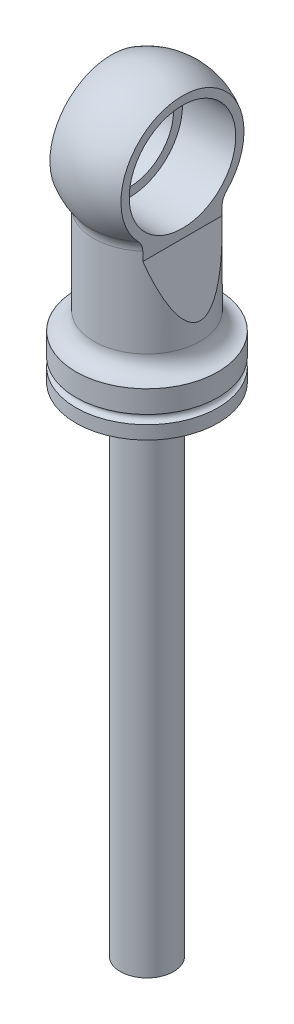
from build123d import *

# Parameters (mm, degrees)
EXTRUDE1_DEPTH      = 13.7
EXTRUDE1_DEPTH_BACK = 13.7
SKETCH4_R           = 7.9375
EXTRUDE3_DEPTH      = 13.7
EXTRUDE3_DEPTH_BACK = 13.7
SKETCH5_R           = 9.525
EXTRUDE4_DEPTH      = 16.875
SKETCH6_R           = 4.7625
EXTRUDE5_DEPTH      = 88.9


with BuildPart() as part:
    # Sketch1 → Revolve1 (revolve)
    with BuildSketch(Plane.XY):
        with BuildLine():
            Line((-9.525, -9.516529567), (-9.525, -25.4254))
            ThreePointArc((-9.525, -25.4254), (-10.447496482, -27.652503518), (-12.6746, -28.575))
            Line((-12.6746, -28.575), (-12.7, -28.575))
            Line((-12.7, -28.575), (-12.7, -32.54375))
            ThreePointArc((-12.7, -32.54375), (-11.90625, -33.3375), (-12.7, -34.13125))
            Line((-12.7, -34.13125), (-12.7, -36.5125))
            Line((-12.7, -36.5125), (0, -36.5125))
            Line((0, -36.5125), (0, 12.7))
            ThreePointArc((0, 12.7), (-11.360741372, 5.676579559), (-10.155929487, -7.625424333))
            ThreePointArc((-10.155929487, -7.625424333), (-9.68689312, -8.519740845), (-9.525, -9.516529567))
        make_face()
    revolve(axis=Axis((0, 29.568581121, 0), (0, -1, 0)))

    # Sketch2 → Extrude1 (cut, two sides)
    with BuildSketch(Plane.XY) as extrude1_sk:
        Polygon((-6.35, 10.998522628), (-6.35, -11.1125), (-9.525, -22.225), (-17.461272298, -22.225), (-17.461272298, 15.422387348), (17.461272298, 15.422387348), (17.461272298, -22.225), (9.525, -22.225), (6.35, -11.1125), (6.35, 10.998522628), (6.35, 13.9933427), (-6.35, 13.9933427), align=None)
    extrude(amount=EXTRUDE1_DEPTH, mode=Mode.SUBTRACT)
    extrude(extrude1_sk.sketch, amount=-EXTRUDE1_DEPTH_BACK, mode=Mode.SUBTRACT)

    # Sketch4 → Extrude3 (cut, two sides)
    with BuildSketch(Plane(origin=(0, 0, 0), x_dir=(0, 0, -1), z_dir=(1, 0, 0))) as extrude3_sk:
        Circle(SKETCH4_R)
    extrude(amount=EXTRUDE3_DEPTH, mode=Mode.SUBTRACT)
    extrude(extrude3_sk.sketch, amount=-EXTRUDE3_DEPTH_BACK, mode=Mode.SUBTRACT)

    # Sketch5 → Extrude4 (cut, through all)
    with BuildSketch(Plane.ZY.offset(3.175)):
        Circle(SKETCH5_R)
    extrude(amount=-EXTRUDE4_DEPTH, mode=Mode.SUBTRACT)

    # Sketch6 → Extrude5 (add)
    with BuildSketch(Plane.XZ.offset(36.5125)):
        Circle(SKETCH6_R)
    extrude(amount=EXTRUDE5_DEPTH)


solid = part.part
